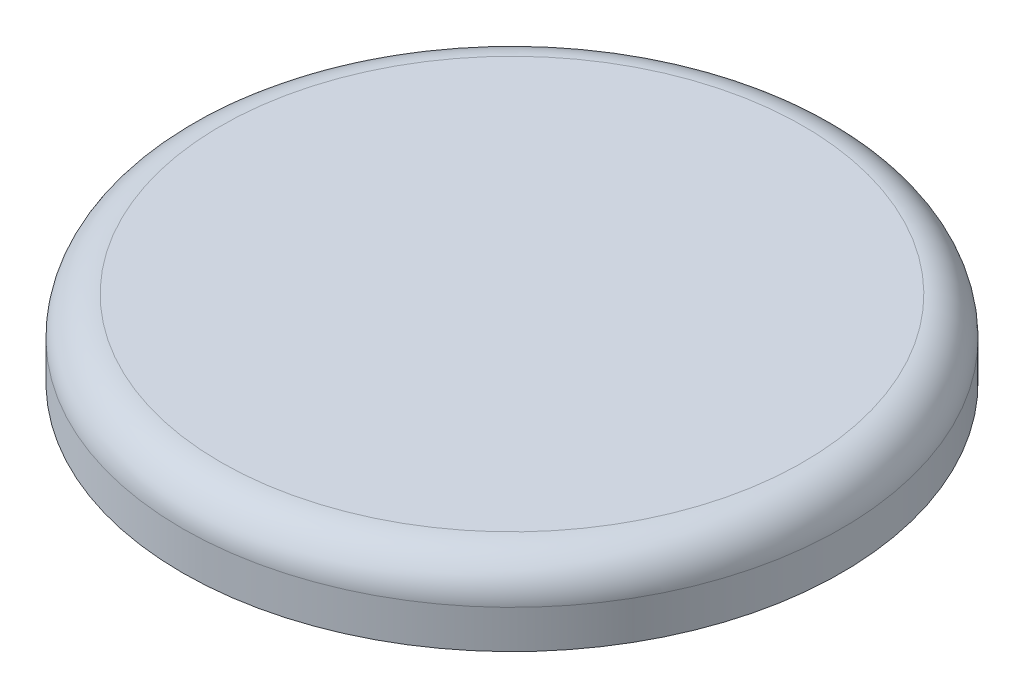
from build123d import *

# Parameters (mm, degrees)
SKETCH1_R           = 8.6
BOSS_EXTRUDE1_DEPTH = 2
FILLET1_R           = 1
SHELL1_T            = -0.2


with BuildPart() as part:
    # Sketch1 → Boss-Extrude1 (new body)
    with BuildSketch(Plane(origin=(0, 0, 0), x_dir=(1, 0, 0), z_dir=(0, 1, 0))):
        with Locations(Location((0, 0, 0), (0, 0, 270))):
            Circle(SKETCH1_R)
    extrude(amount=BOSS_EXTRUDE1_DEPTH)

    # Fillet1
    fillet1_edges = [part.edges().sort_by_distance(p)[0] for p in [
        (0, 2, -8.6),
    ]]
    fillet(fillet1_edges, radius=FILLET1_R)

    # Shell1
    shell1_openings = [part.faces().sort_by_distance(p)[0] for p in [
        (0, 0, 0),
    ]]
    offset(amount=SHELL1_T, openings=shell1_openings, kind=Kind.INTERSECTION)


solid = part.part
